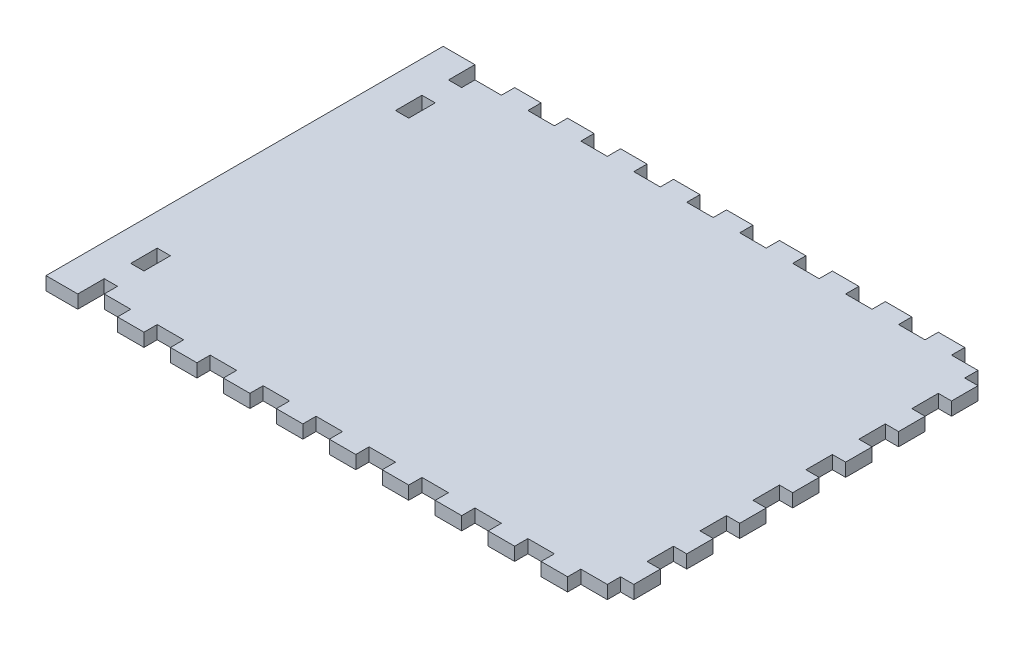
from build123d import *

# Parameters (mm, degrees)
SALIENTE_EXTRUIR1_DEPTH = 5
CROQUIS2_W              = 12
CROQUIS2_H              = 150
SALIENTE_EXTRUIR3_DEPTH = 5


with BuildPart() as part:
    # Croquis1 → Saliente-Extruir1 (new body)
    with BuildSketch(Plane(origin=(0, 0, 0), x_dir=(1, 0, 0), z_dir=(0, 1, 0))):
        Polygon((35, 0), (45, 0), (45, 5), (55, 5), (55, 0), (65, 0), (65, 5), (75, 5), (75, 0), (85, 0), (85, 5), (95, 5), (95, 0), (105, 0), (105, 5), (115, 5), (115, 0), (125, 0), (125, 5), (135, 5), (135, 0), (145, 0), (145, 5), (155, 5), (155, 0), (165, 0), (165, 5), (175, 5), (175, 0), (185, 0), (185, 5), (195, 5), (195, 10), (200, 10), (200, 20), (195, 20), (195, 30), (200, 30), (200, 40), (195, 40), (195, 50), (200, 50), (200, 60), (195, 60), (195, 70), (200, 70), (200, 80), (195, 80), (195, 90), (200, 90), (200, 100), (195, 100), (195, 110), (200, 110), (200, 120), (195, 120), (195, 130), (200, 130), (200, 140), (195, 140), (195, 145), (185, 145), (185, 150), (175, 150), (175, 145), (165, 145), (165, 150), (155, 150), (155, 145), (145, 145), (145, 150), (135, 150), (135, 145), (125, 145), (125, 150), (115, 150), (115, 145), (105, 145), (105, 150), (95, 150), (95, 145), (85, 145), (85, 150), (75, 150), (75, 145), (65, 145), (65, 150), (55, 150), (55, 145), (45, 145), (45, 150), (35, 150), (35, 145), (25, 145), (25, 150), (15, 150), (15, 145), (5, 145), (5, 140), (0, 140), (0, 130), (5, 130), (5, 120), (0, 120), (0, 30), (5, 30), (5, 20), (0, 20), (0, 10), (5, 10), (5, 5), (15, 5), (15, 0), (25, 0), (25, 5), (35, 5), align=None)
    extrude(amount=SALIENTE_EXTRUIR1_DEPTH)

    # Croquis2 → Saliente-Extruir3 (add)
    with BuildSketch(Plane(origin=(0, 5, 0), x_dir=(1, 0, 0), z_dir=(0, 1, 0))):
        with Locations((-6, 75)):
            Rectangle(CROQUIS2_W, CROQUIS2_H)
    extrude(amount=-SALIENTE_EXTRUIR3_DEPTH)


solid = part.part
